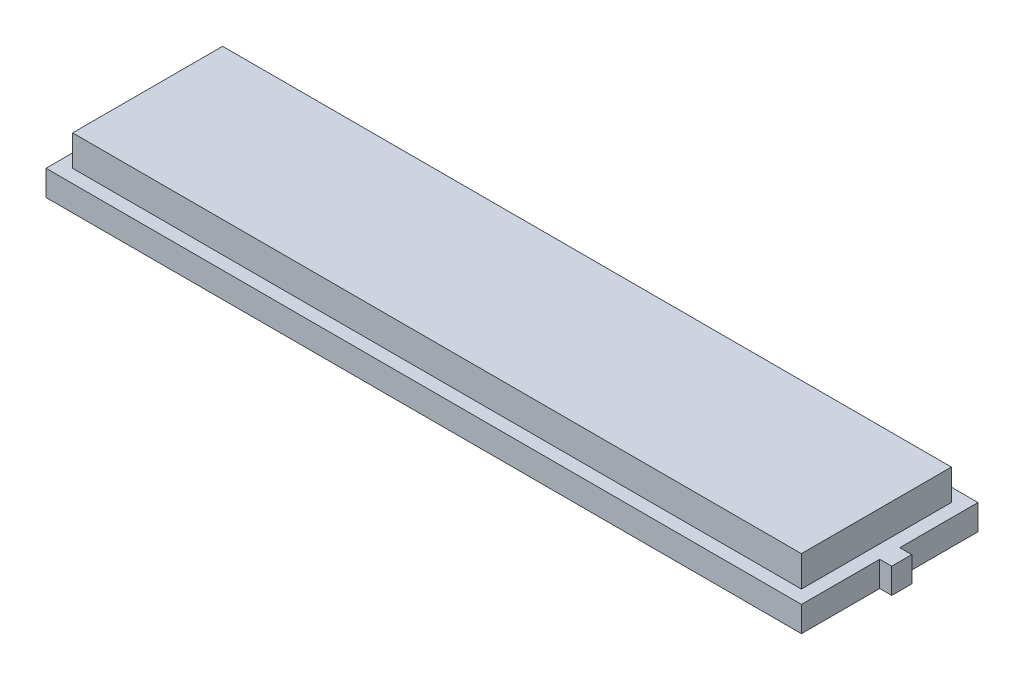
from build123d import *

# Parameters (mm, degrees)
BOSS_EXTRUDE1_DEPTH = 1.9
SKETCH2_W           = 54.62
SKETCH2_H           = 11.24
BOSS_EXTRUDE2_DEPTH = 2.3


with BuildPart() as part:
    # Sketch1 → Boss-Extrude1 (new body)
    with BuildSketch(Plane(origin=(0, 0, 0), x_dir=(1, 0, 0), z_dir=(0, 1, 0))):
        Polygon((28.31, 6.615), (28.31, 0.75), (29.21, 0.75), (29.21, -0.75), (28.31, -0.75), (28.31, -6.615), (-28.31, -6.615), (-28.31, 6.615), align=None)
    extrude(amount=BOSS_EXTRUDE1_DEPTH)

    # Sketch2 → Boss-Extrude2 (add)
    with BuildSketch(Plane(origin=(0, 1.9, 0), x_dir=(1, 0, 0), z_dir=(0, 1, 0))):
        Rectangle(SKETCH2_W, SKETCH2_H)
    extrude(amount=BOSS_EXTRUDE2_DEPTH)


solid = part.part
